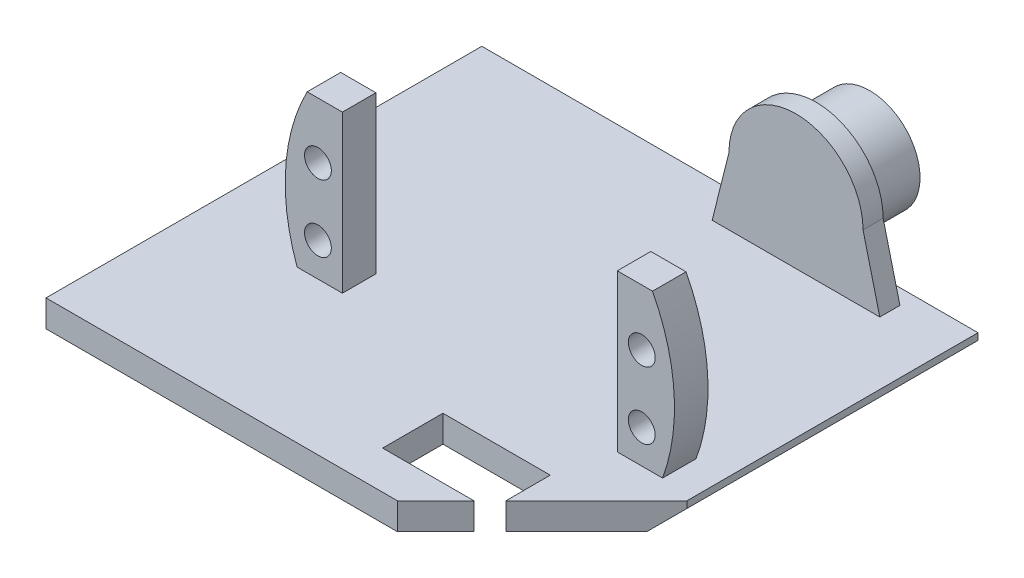
from build123d import *

# Parameters (mm, degrees)
SALIENTE_EXTRUIR1_DEPTH = 4
CROQUIS2_W              = 6.75
CROQUIS2_H              = 5
SALIENTE_EXTRUIR2_DEPTH = 18
CROQUIS3_R              = 2
CORTAR_EXTRUIR1_DEPTH   = 10
SALIENTE_EXTRUIR3_DEPTH = 5
CROQUIS6_W              = 25
CROQUIS6_H              = 3
SALIENTE_EXTRUIR4_DEPTH = 20
CROQUIS7_R              = 7.5
SALIENTE_EXTRUIR5_DEPTH = 8
CORTAR_EXTRUIR2_DEPTH   = 3
CORTAR_EXTRUIR3_REACH   = 6
CROQUIS9_W              = 16
CROQUIS9_H              = 9
CHAFL_N1_SIZE           = 3


with BuildPart() as part:
    # Croquis1 → Saliente-Extruir1 (new body)
    with BuildSketch(Plane(origin=(0, 0, 0), x_dir=(1, 0, 0), z_dir=(0, 1, 0))):
        Polygon((12.331887662, -35.204744953), (33.9207519, -13.615880715), (33.9207519, 29.795255047), (-40.0792481, 29.795255047), (-40.0792481, -35.204744953), align=None)
    extrude(amount=SALIENTE_EXTRUIR1_DEPTH)

    # Croquis2 → Saliente-Extruir2 (add)
    with BuildSketch(Plane(origin=(0, 4, 0), x_dir=(1, 0, 0), z_dir=(0, 1, 0))):
        with Locations((-21.9542481, -10)):
            Rectangle(CROQUIS2_W, CROQUIS2_H)
        with Locations((25.7957519, -10)):
            Rectangle(CROQUIS2_W, CROQUIS2_H)
    extrude(amount=SALIENTE_EXTRUIR2_DEPTH)

    # Croquis3 → Cortar-Extruir1 (cut)
    with BuildSketch(Plane.XY.offset(12.5)):
        with Locations((-22.2292481, 9)):
            Circle(CROQUIS3_R)
        with Locations((-22.2292481, 19)):
            Circle(CROQUIS3_R)
        with Locations((26.0707519, 19)):
            Circle(CROQUIS3_R)
        with Locations((26.0707519, 9)):
            Circle(CROQUIS3_R)
    extrude(amount=-CORTAR_EXTRUIR1_DEPTH, mode=Mode.SUBTRACT)

    # Croquis5 → Saliente-Extruir3 (add)
    with BuildSketch(Plane.XY.offset(12.5)):
        with BuildLine():
            Line((-25.3292481, 4), (-25.3292481, 22))
            Line((-25.3292481, 22), (-18.5792481, 22))
            Line((-18.5792481, 22), (-18.5792481, 27.393443103))
            Line((-18.5792481, 27.393443103), (-23.831494252, 27.393443103))
            ThreePointArc((-23.831494252, 27.393443103), (-27.046864835, 15.854637612), (-25.3292481, 4))
        make_face()
        with BuildLine():
            Line((29.1707519, 4), (29.1707519, 22))
            Line((29.1707519, 22), (22.4207519, 22))
            Line((22.4207519, 22), (22.4207519, 27.393443103))
            Line((22.4207519, 27.393443103), (27.672998052, 27.393443103))
            ThreePointArc((27.672998052, 27.393443103), (30.888368635, 15.854637612), (29.1707519, 4))
        make_face()
    extrude(amount=-SALIENTE_EXTRUIR3_DEPTH)

    # Croquis6 → Saliente-Extruir4 (add)
    with BuildSketch(Plane(origin=(0, 4, 0), x_dir=(1, 0, 0), z_dir=(0, 1, 0))):
        with Locations((12.0707519, 26)):
            Rectangle(CROQUIS6_W, CROQUIS6_H)
    extrude(amount=SALIENTE_EXTRUIR4_DEPTH)

    # Croquis7 → Saliente-Extruir5 (add)
    with BuildSketch(Plane(origin=(0, 0, -27.5), x_dir=(-1, 0, 0), z_dir=(0, 0, -1))):
        with Locations((-12.0707519, 14)):
            Circle(CROQUIS7_R)
    extrude(amount=SALIENTE_EXTRUIR5_DEPTH)

    # Croquis8 → Cortar-Extruir2 (cut)
    with BuildSketch(Plane(origin=(0, 0, -27.5), x_dir=(-1, 0, 0), z_dir=(0, 0, -1))):
        with BuildLine():
            Line((-24.5707519, 24), (-24.5707519, 4))
            Line((-24.5707519, 4), (-22.0707519, 14))
            ThreePointArc((-22.0707519, 14), (-19.141819712, 21.071067812), (-12.0707519, 24))
            Line((-12.0707519, 24), (-24.5707519, 24))
        make_face()
        with BuildLine():
            Line((0.4292481, 24), (-12.0707519, 24))
            ThreePointArc((-12.0707519, 24), (-4.999684088, 21.071067812), (-2.0707519, 14))
            Line((-2.0707519, 14), (0.4292481, 4))
            Line((0.4292481, 4), (0.4292481, 24))
        make_face()
    extrude(amount=-CORTAR_EXTRUIR2_DEPTH, mode=Mode.SUBTRACT)

    # Croquis9 → Cortar-Extruir3 (cut, up to next)
    with BuildSketch(Plane(origin=(0, 4, 0), x_dir=(1, 0, 0), z_dir=(0, 1, 0)), mode=Mode.PRIVATE) as cortar_extruir3_sk1:
        with Locations((12.4207519, -25)):
            Rectangle(CROQUIS9_W, CROQUIS9_H)
    cortar_extruir3_tool1 = extrude(cortar_extruir3_sk1.sketch, amount=-CORTAR_EXTRUIR3_REACH, mode=Mode.PRIVATE) & part.part
    add(cortar_extruir3_tool1.solids().sort_by_distance((12.420752, 4, 25))[0], mode=Mode.SUBTRACT)

    # Chaflán1
    chafl_n1_edges = [part.edges().sort_by_distance(p)[0] for p in [
        (33.9207519, 0, -8.089687166),
    ]]
    chamfer(chafl_n1_edges, length=CHAFL_N1_SIZE)


solid = part.part
